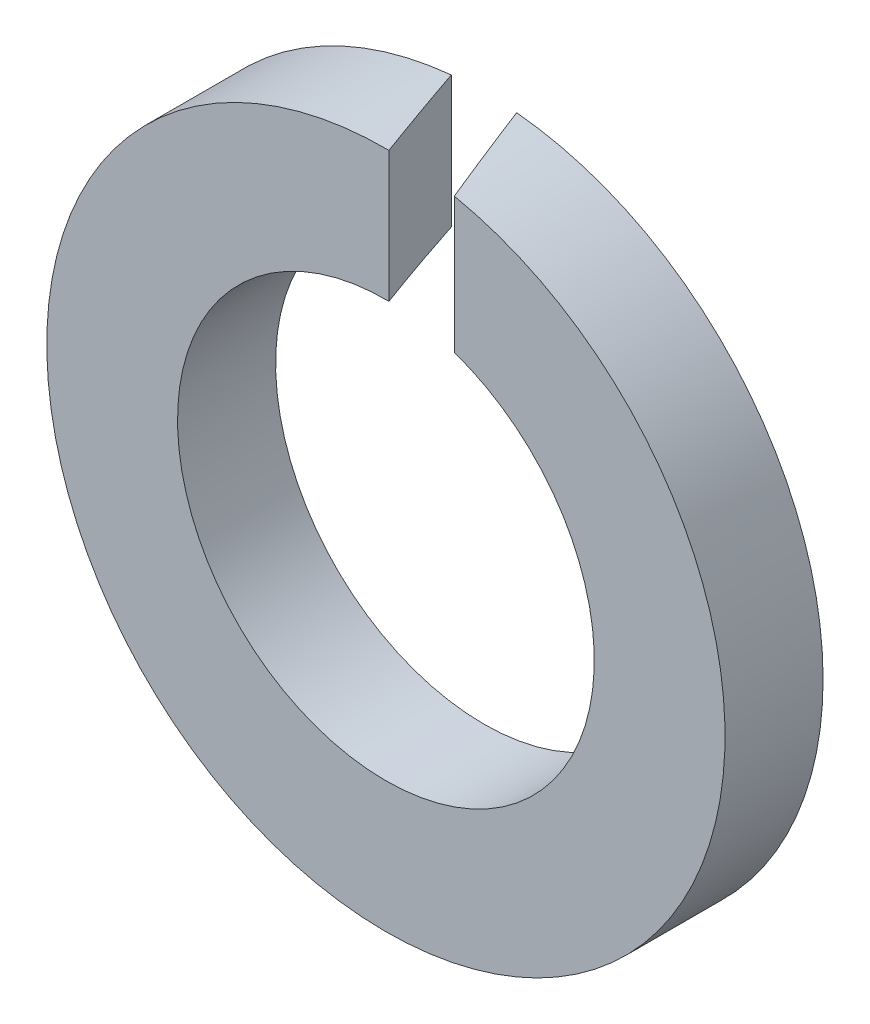
from build123d import *

# Parameters (mm, degrees)
SKETCH_1_R          = 4.15
SKETCH_1_R_2        = 2.55
EXTRUDE_1_DEPTH     = 1.2
CUT_EXTRUDE_3_DEPTH = 5.15


with BuildPart() as part:
    # Эскиз1 → Вытянуть1 (new body)
    with BuildSketch(Plane.XY):
        Circle(SKETCH_1_R)
        Circle(SKETCH_1_R_2, mode=Mode.SUBTRACT)
    extrude(amount=EXTRUDE_1_DEPTH)

    # Эскиз2 → Вырез-Вытянуть3 (cut, through all)
    with BuildSketch(Plane(origin=(0, 0, 0), x_dir=(1, 0, 0), z_dir=(0, 1, 0))):
        Polygon((-0.652013767, 0.692402135), (0.143129689, 0.705745378), (1.483833106, -2.977806984), (0.772221758, -3.220652811), align=None)
    extrude(amount=CUT_EXTRUDE_3_DEPTH, mode=Mode.SUBTRACT)


solid = part.part
